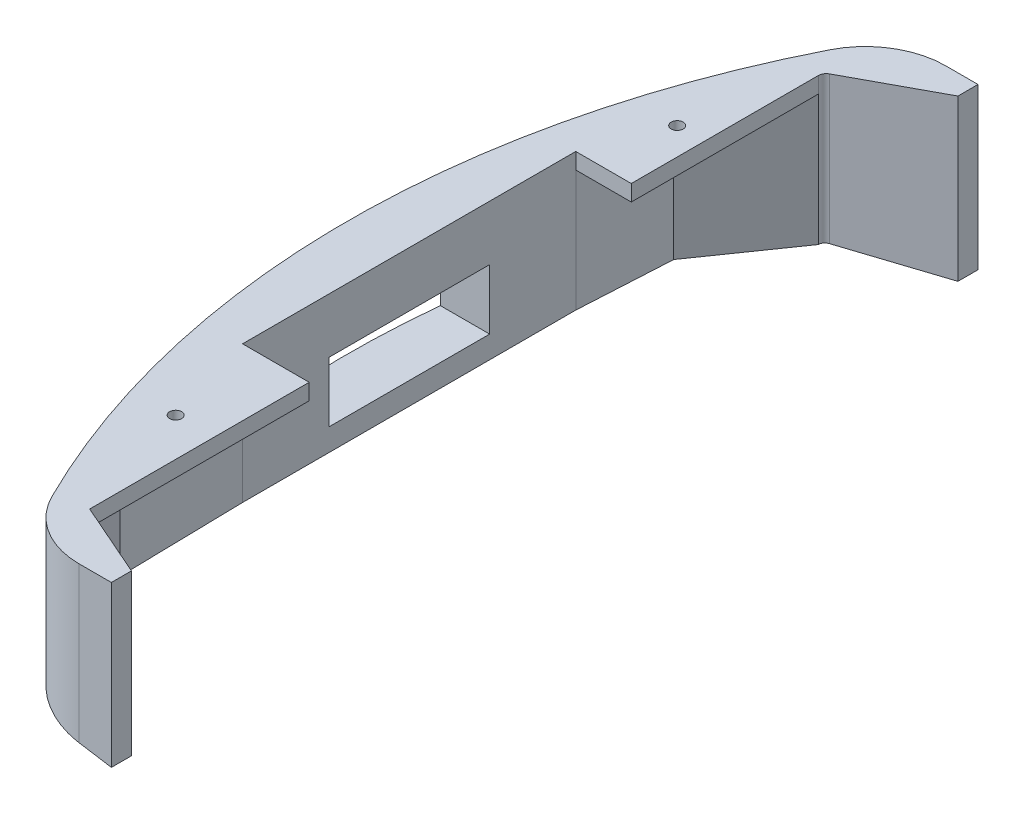
from build123d import *

# Parameters (mm, degrees)
FRONT_SKETCH_R      = 1.905
BOSS_EXTRUDE1_DEPTH = 50.8
CUT_EXTRUDE1_START  = -53.34
CUT_EXTRUDE1_DEPTH  = 48.26
CUT_EXTRUDE2_DEPTH  = 274.638700861
SKETCH3_R           = 3.175
CUT_EXTRUDE3_DEPTH  = 18.03621965
SKETCH4_W           = 50.8
SKETCH4_H           = 19.05
CUT_EXTRUDE4_DEPTH  = 22.86


with BuildPart() as part:
    # front_sketch → Boss-Extrude1 (new body)
    with BuildSketch(Plane(origin=(0, 0, 0), x_dir=(1, 0, 0), z_dir=(0, 1, 0))):
        with BuildLine():
            Line((-94.961375831, 124.478458264), (-121.345326632, 110.234521439))
            ThreePointArc((-121.345326632, 110.234521439), (-122.32001306, 109.300728329), (-122.678671172, 107.99944144))
            Line((-122.678671172, 107.99944144), (-122.678671172, 48.810796684))
            Line((-122.678671172, 48.810796684), (-140.250849959, 48.810796684))
            Line((-140.250849959, 48.810796684), (-140.250849959, -56.645199257))
            Line((-140.250849959, -56.645199257), (-119.167015715, -56.645199257))
            Line((-119.167015715, -56.645199257), (-119.167015715, -126.112255785))
            Line((-119.167015715, -126.112255785), (-95.601645083, -136.460242597))
            Line((-95.601645083, -136.460242597), (-95.601645083, -142.810242597))
            Line((-95.601645083, -142.810242597), (-105.798207048, -142.810242597))
            ThreePointArc((-105.798207048, -142.810242597), (-119.167015715, -139.007347839), (-128.532661201, -128.737404395))
            ThreePointArc((-128.532661201, -128.737404395), (-157.286213724, -5.861503432), (-127.918775374, 116.869125935))
            ThreePointArc((-127.918775374, 116.869125935), (-118.556014486, 127.058910858), (-105.241228699, 130.828458264))
            Line((-105.241228699, 130.828458264), (-94.961375831, 130.828458264))
            Line((-94.961375831, 130.828458264), (-94.961375831, 124.478458264))
        make_face()
        with Locations((-131.296368682, 71.963600743)):
            Circle(FRONT_SKETCH_R, mode=Mode.SUBTRACT)
        with Locations((-131.296368682, -86.786399257)):
            Circle(FRONT_SKETCH_R, mode=Mode.SUBTRACT)
    extrude(amount=BOSS_EXTRUDE1_DEPTH)

    # Sketch1 → Cut-Extrude1 (cut)
    with BuildSketch(Plane(origin=(0, 50.8, 0), x_dir=(1, 0, 0), z_dir=(0, 1, 0)).offset(CUT_EXTRUDE1_START)):
        Polygon((-122.678671172, 48.810796684), (-122.678671172, 107.99944144), (-138.833286115, 78.405119062), (-140.250849959, 48.810796684), align=None)
        Polygon((-119.167015715, -56.645199257), (-140.250849959, -56.645199257), (-139.542068037, -96.192486205), (-119.167015715, -126.112255785), align=None)
    extrude(amount=CUT_EXTRUDE1_DEPTH, mode=Mode.SUBTRACT)

    # Sketch2 → Cut-Extrude2 (cut, through all)
    with BuildSketch(Plane.XY.offset(142.810242597)):
        Polygon((-94.961375831, 0), (-157.287069608, 0), (-157.287069608, 10.05650125), align=None)
    extrude(amount=-CUT_EXTRUDE2_DEPTH, mode=Mode.SUBTRACT)

    # Sketch3 → Cut-Extrude3 (cut, through all)
    with BuildSketch(Plane(origin=(-140.250849959, 0, 0), x_dir=(0, 0, -1), z_dir=(1, 0, 0))):
        with Locations((-17.312177426, 23.984839343)):
            Circle(SKETCH3_R)
        with Locations((11.274067854, 23.984839343)):
            Circle(SKETCH3_R)
    extrude(amount=-CUT_EXTRUDE3_DEPTH, mode=Mode.SUBTRACT)

    # Sketch4 → Cut-Extrude4 (cut)
    with BuildSketch(Plane(origin=(-140.250849959, 0, 0), x_dir=(0, 0, -1), z_dir=(1, 0, 0))):
        with Locations((-3.8461352, 23.892272696)):
            Rectangle(SKETCH4_W, SKETCH4_H)
    extrude(amount=-CUT_EXTRUDE4_DEPTH, mode=Mode.SUBTRACT)


solid = part.part
